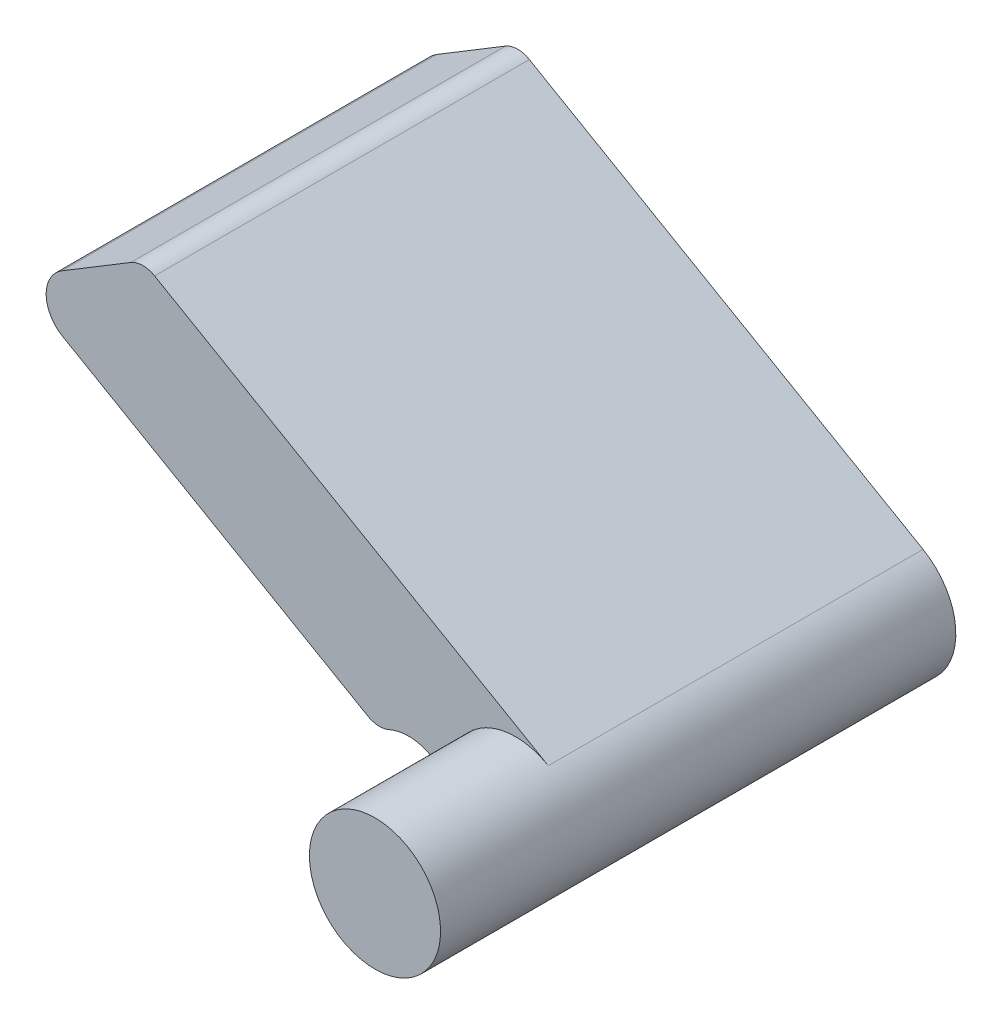
from build123d import *

# Parameters (mm, degrees)
EXTRUDE_1_DEPTH = 8
FILLET_1_R      = 0.5
FILLET_2_R      = 0.7
EXTRUDE_START   = -8
SKETCH_2_R      = 1.4
EXTRUDE_2_DEPTH = 3


with BuildPart() as part:
    # 草图1 → 凸台-拉伸1 (new body)
    with BuildSketch(Plane.XY):
        with BuildLine():
            Line((0.7, 1.212435565), (-7.960254038, 6.212435565))
            Line((-7.960254038, 6.212435565), (-10.694228634, 4.557735027))
            Line((-10.694228634, 4.557735027), (-2.9, 0.057735027))
            ThreePointArc((-2.9, 0.057735027), (-1.990417738, 0.223935223), (-1.333398647, -0.426670889))
            ThreePointArc((-1.333398647, -0.426670889), (0.878615931, -1.089969746), (0.7, 1.212435565))
        make_face()
    extrude(amount=EXTRUDE_1_DEPTH)

    # 圆角1
    fillet_1_edges = [part.edges().sort_by_distance(p)[0] for p in [
        (-7.960254038, 6.212435565, 4),
        (-2.9, 0.057735027, 4),
    ]]
    fillet(fillet_1_edges, radius=FILLET_1_R)

    # 圆角2
    fillet_2_edges = [part.edges().sort_by_distance(p)[0] for p in [
        (-10.694228634, 4.557735027, 4),
    ]]
    fillet(fillet_2_edges, radius=FILLET_2_R)

    # 草图2 → 凸台-拉伸2 (add)
    with BuildSketch(Plane(origin=(0, 0, 0), x_dir=(-1, 0, 0), z_dir=(0, 0, -1)).offset(EXTRUDE_START)):
        Circle(SKETCH_2_R)
    extrude(amount=-EXTRUDE_2_DEPTH)


solid = part.part
